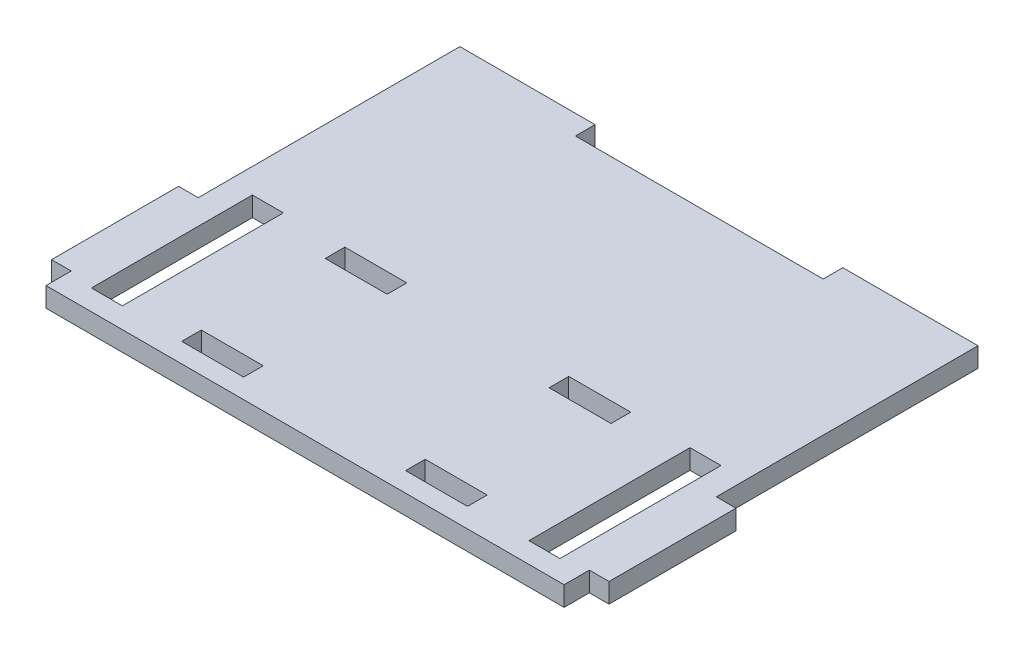
from build123d import *

# Parameters (mm, degrees)
SKETCH1_W           = 21.825
SKETCH1_H           = 3.175
SKETCH1_W_2         = 3.175
SKETCH1_H_2         = 20.5
BOSS_EXTRUDE1_DEPTH = 3.175
SKETCH2_W           = 5
SKETCH2_H           = 26
SKETCH2_W_2         = 10
SKETCH2_H_2         = 3.175
CUT_EXTRUDE1_DEPTH  = 23.175


with BuildPart() as part:
    # Sketch1 → Boss-Extrude1 (new body)
    with BuildSketch(Plane(origin=(0, 0, 0), x_dir=(1, 0, 0), z_dir=(0, 1, 0))):
        Polygon((-20, 31.825), (-41.825, 31.825), (-41.825, -7.25), (-41.825, -27.75), (-41.825, -31.825), (-20, -31.825), (20, -31.825), (41.825, -31.825), (41.825, -27.75), (41.825, -7.25), (41.825, 31.825), (20, 31.825), align=None)
        with Locations((30.9125, 33.4125)):
            Rectangle(SKETCH1_W, SKETCH1_H)
        with Locations((-30.9125, 33.4125)):
            Rectangle(SKETCH1_W, SKETCH1_H)
        with Locations((-43.4125, -17.5)):
            Rectangle(SKETCH1_W_2, SKETCH1_H_2)
        with Locations((43.4125, -17.5)):
            Rectangle(SKETCH1_W_2, SKETCH1_H_2)
    extrude(amount=BOSS_EXTRUDE1_DEPTH)

    # Sketch2 → Cut-Extrude1 (cut)
    with BuildSketch(Plane(origin=(0, 3.175, 0), x_dir=(1, 0, 0), z_dir=(0, 1, 0))):
        with Locations((-35.325, -15.5)):
            Rectangle(SKETCH2_W, SKETCH2_H)
        with Locations((35.325, -15.5)):
            Rectangle(SKETCH2_W, SKETCH2_H)
        with Locations((-18.075, -3.9125)):
            Rectangle(SKETCH2_W_2, SKETCH2_H_2)
        with Locations((18.075, -3.9125)):
            Rectangle(SKETCH2_W_2, SKETCH2_H_2)
        with Locations((18.075, -27.0875)):
            Rectangle(SKETCH2_W_2, SKETCH2_H_2)
        with Locations((-18.075, -27.0875)):
            Rectangle(SKETCH2_W_2, SKETCH2_H_2)
    extrude(amount=-CUT_EXTRUDE1_DEPTH, mode=Mode.SUBTRACT)


solid = part.part
